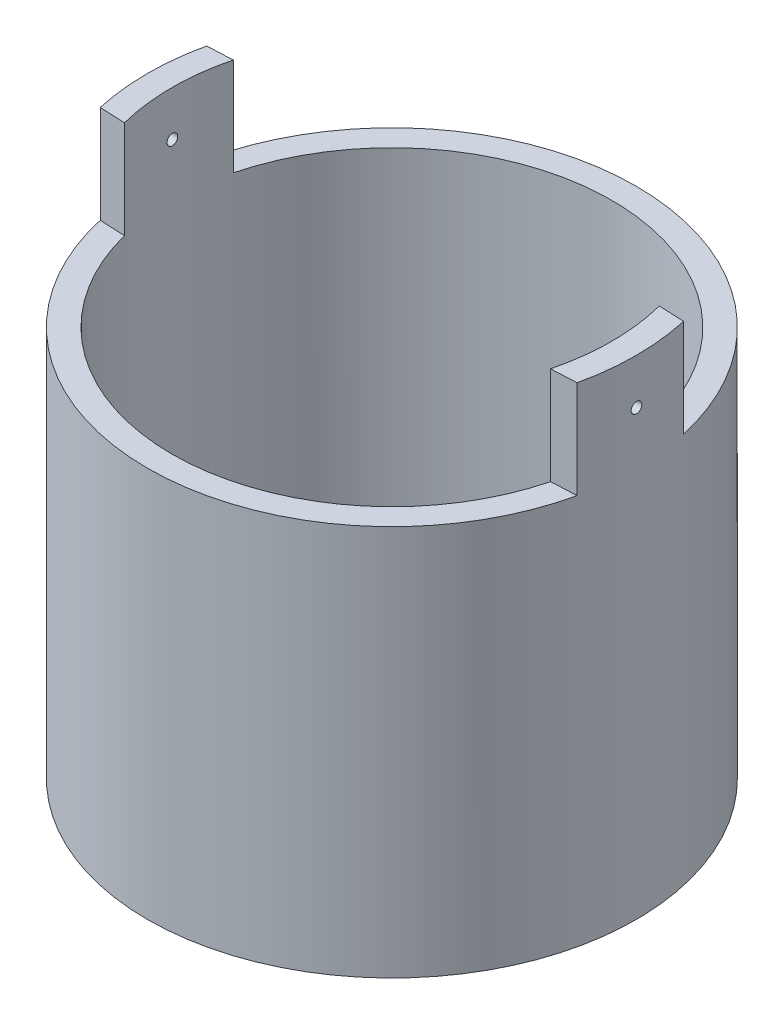
from build123d import *

# Parameters (mm, degrees)
SKETCH1_R           = 63.5
BOSS_EXTRUDE1_DEPTH = 76.2
SKETCH2_R           = 57.15
CUT_EXTRUDE1_DEPTH  = 69.85
SKETCH4_R           = 25.4
BOSS_EXTRUDE2_DEPTH = 25.4
SKETCH5_R           = 22.225
CUT_EXTRUDE2_DEPTH  = 2514.6
SKETCH8_R           = 63.5
BOSS_EXTRUDE3_DEPTH = 25.4
SKETCH9_R           = 57.15
CUT_EXTRUDE3_DEPTH  = 50.8
BOSS_EXTRUDE5_DEPTH = 25.4
BOSS_EXTRUDE6_DEPTH = 25.4
SKETCH14_R          = 1.389063
CUT_EXTRUDE4_DEPTH  = 2514.6


with BuildPart() as part:
    # Sketch1 → Boss-Extrude1 (new body)
    with BuildSketch(Plane(origin=(0, 0, 0), x_dir=(1, 0, 0), z_dir=(0, 1, 0))):
        Circle(SKETCH1_R)
    extrude(amount=BOSS_EXTRUDE1_DEPTH)

    # Sketch2 → Cut-Extrude1 (cut)
    with BuildSketch(Plane(origin=(0, 76.2, 0), x_dir=(1, 0, 0), z_dir=(0, 1, 0))):
        Circle(SKETCH2_R)
    extrude(amount=-CUT_EXTRUDE1_DEPTH, mode=Mode.SUBTRACT)

    # Sketch4 → Boss-Extrude2 (add)
    with BuildSketch(Plane.XZ):
        Circle(SKETCH4_R)
    extrude(amount=BOSS_EXTRUDE2_DEPTH)

    # Sketch5 → Cut-Extrude2 (cut)
    with BuildSketch(Plane.XZ.offset(25.4)):
        Circle(SKETCH5_R)
    extrude(amount=-CUT_EXTRUDE2_DEPTH, mode=Mode.SUBTRACT)

    # Sketch8 → Boss-Extrude3 (add)
    with BuildSketch(Plane(origin=(0, 76.2, 0), x_dir=(1, 0, 0), z_dir=(0, 1, 0))):
        Circle(SKETCH8_R)
    extrude(amount=BOSS_EXTRUDE3_DEPTH)

    # Sketch9 → Cut-Extrude3 (cut)
    with BuildSketch(Plane(origin=(0, 101.6, 0), x_dir=(1, 0, 0), z_dir=(0, 1, 0))):
        Circle(SKETCH9_R)
    extrude(amount=-CUT_EXTRUDE3_DEPTH, mode=Mode.SUBTRACT)

    # Sketch11 → Boss-Extrude5 (add)
    with BuildSketch(Plane(origin=(0, 101.6, 0), x_dir=(1, 0, 0), z_dir=(0, 1, 0))):
        with BuildLine():
            Line((-61.976, 13.828428), (-55.372, 14.144402))
            ThreePointArc((-55.372, 14.144402), (-57.15, 0), (-55.372, -14.144402))
            Line((-55.372, -14.144402), (-61.976, -13.828428))
            ThreePointArc((-61.976, -13.828428), (-63.5, 0), (-61.976, 13.828428))
        make_face()
    extrude(amount=BOSS_EXTRUDE5_DEPTH)

    # Sketch13 → Boss-Extrude6 (add)
    with BuildSketch(Plane(origin=(0, 101.6, 0), x_dir=(1, 0, 0), z_dir=(0, 1, 0))):
        with BuildLine():
            Line((55.372, 14.144402), (61.976, 13.828428))
            ThreePointArc((61.976, 13.828428), (63.5, 0), (61.976, -13.828428))
            Line((61.976, -13.828428), (55.372, -14.144402))
            ThreePointArc((55.372, -14.144402), (57.15, 0), (55.372, 14.144402))
        make_face()
    extrude(amount=BOSS_EXTRUDE6_DEPTH)

    # Sketch14 → Cut-Extrude4 (cut)
    with BuildSketch(Plane(origin=(101.6, 0, 0), x_dir=(0, 0, -1), z_dir=(1, 0, 0))):
        with Locations((0.081717, 115.219319)):
            Circle(SKETCH14_R)
    extrude(amount=-CUT_EXTRUDE4_DEPTH, mode=Mode.SUBTRACT)


solid = part.part
